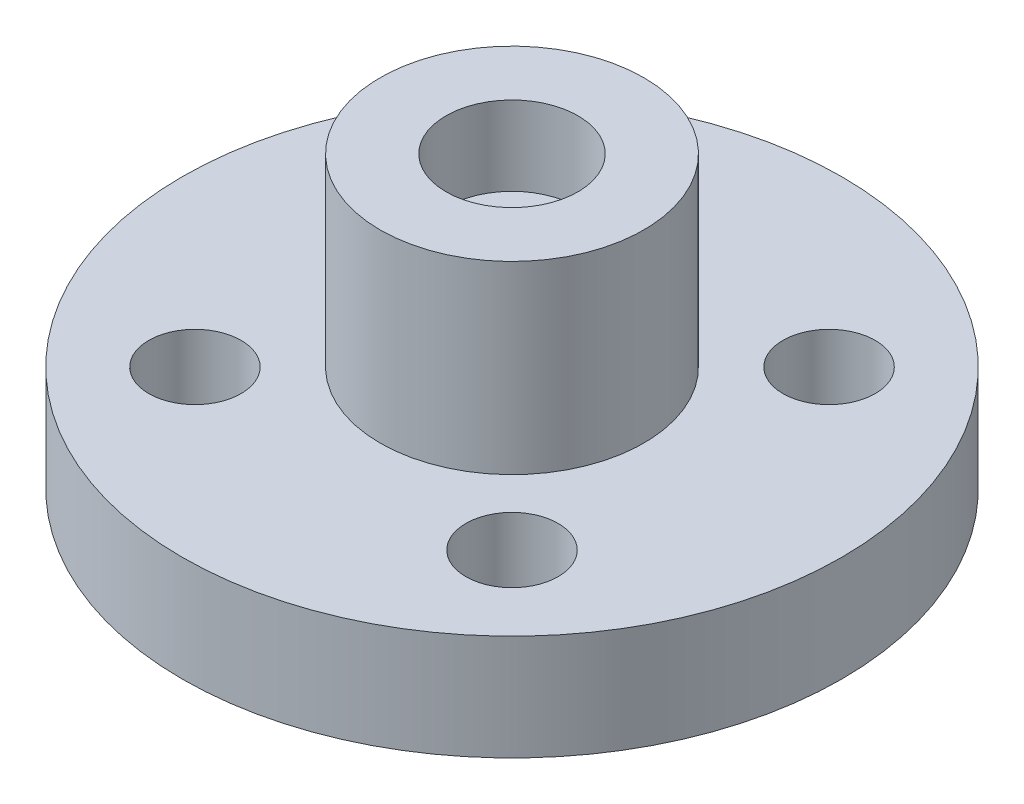
from build123d import *

# Parameters (mm, degrees)
SKETCH1_R           = 12.5
BOSS_EXTRUDE1_DEPTH = 4
SKETCH2_R           = 5
SKETCH2_R_2         = 2.5
BOSS_EXTRUDE2_DEPTH = 7
CUT_EXTRUDE1_REACH  = 21.013
SKETCH3_R           = 1.75
SKETCH2_2_R         = 2.5
BOSS_EXTRUDE3_DEPTH = 4


with BuildPart() as part:
    # Sketch1 → Boss-Extrude1 (new body)
    with BuildSketch(Plane(origin=(0, 0, 0), x_dir=(1, 0, 0), z_dir=(0, 1, 0))):
        Circle(SKETCH1_R)
    extrude(amount=BOSS_EXTRUDE1_DEPTH)

    # Sketch2 → Boss-Extrude2 (add)
    with BuildSketch(Plane(origin=(0, 4, 0), x_dir=(1, 0, 0), z_dir=(0, 1, 0))):
        Circle(SKETCH2_R)
        Circle(SKETCH2_R_2, mode=Mode.SUBTRACT)
    extrude(amount=BOSS_EXTRUDE2_DEPTH)

    # Sketch3 → Cut-Extrude1 (cut, up to next)
    with BuildSketch(Plane(origin=(0, 4, 0), x_dir=(1, 0, 0), z_dir=(0, 1, 0)), mode=Mode.PRIVATE) as cut_extrude1_sk1:
        with Locations((-6.01040764, 6.01040764)):
            Circle(SKETCH3_R)
    cut_extrude1_tool1 = extrude(cut_extrude1_sk1.sketch, amount=-CUT_EXTRUDE1_REACH, mode=Mode.PRIVATE) & part.part
    # Sketch3 → Cut-Extrude1 (cut, up to next)
    with BuildSketch(Plane(origin=(0, 4, 0), x_dir=(1, 0, 0), z_dir=(0, 1, 0)), mode=Mode.PRIVATE) as cut_extrude1_sk2:
        with Locations((6.01040764, 6.01040764)):
            Circle(SKETCH3_R)
    cut_extrude1_tool2 = extrude(cut_extrude1_sk2.sketch, amount=-CUT_EXTRUDE1_REACH, mode=Mode.PRIVATE) & part.part
    # Sketch3 → Cut-Extrude1 (cut, up to next)
    with BuildSketch(Plane(origin=(0, 4, 0), x_dir=(1, 0, 0), z_dir=(0, 1, 0)), mode=Mode.PRIVATE) as cut_extrude1_sk3:
        with Locations((6.01040764, -6.01040764)):
            Circle(SKETCH3_R)
    cut_extrude1_tool3 = extrude(cut_extrude1_sk3.sketch, amount=-CUT_EXTRUDE1_REACH, mode=Mode.PRIVATE) & part.part
    # Sketch3 → Cut-Extrude1 (cut, up to next)
    with BuildSketch(Plane(origin=(0, 4, 0), x_dir=(1, 0, 0), z_dir=(0, 1, 0)), mode=Mode.PRIVATE) as cut_extrude1_sk4:
        with Locations((-6.01040764, -6.01040764)):
            Circle(SKETCH3_R)
    cut_extrude1_tool4 = extrude(cut_extrude1_sk4.sketch, amount=-CUT_EXTRUDE1_REACH, mode=Mode.PRIVATE) & part.part
    add(cut_extrude1_tool1.solids().sort_by_distance((-6.010408, 4, -6.010408))[0], mode=Mode.SUBTRACT)
    add(cut_extrude1_tool2.solids().sort_by_distance((6.010408, 4, -6.010408))[0], mode=Mode.SUBTRACT)
    add(cut_extrude1_tool3.solids().sort_by_distance((6.010408, 4, 6.010408))[0], mode=Mode.SUBTRACT)
    add(cut_extrude1_tool4.solids().sort_by_distance((-6.010408, 4, 6.010408))[0], mode=Mode.SUBTRACT)

    # Sketch2_2 → Boss-Extrude3 (add)
    with BuildSketch(Plane(origin=(0, 4, 0), x_dir=(1, 0, 0), z_dir=(0, 1, 0))):
        Circle(SKETCH2_2_R)
    extrude(amount=BOSS_EXTRUDE3_DEPTH)


solid = part.part
